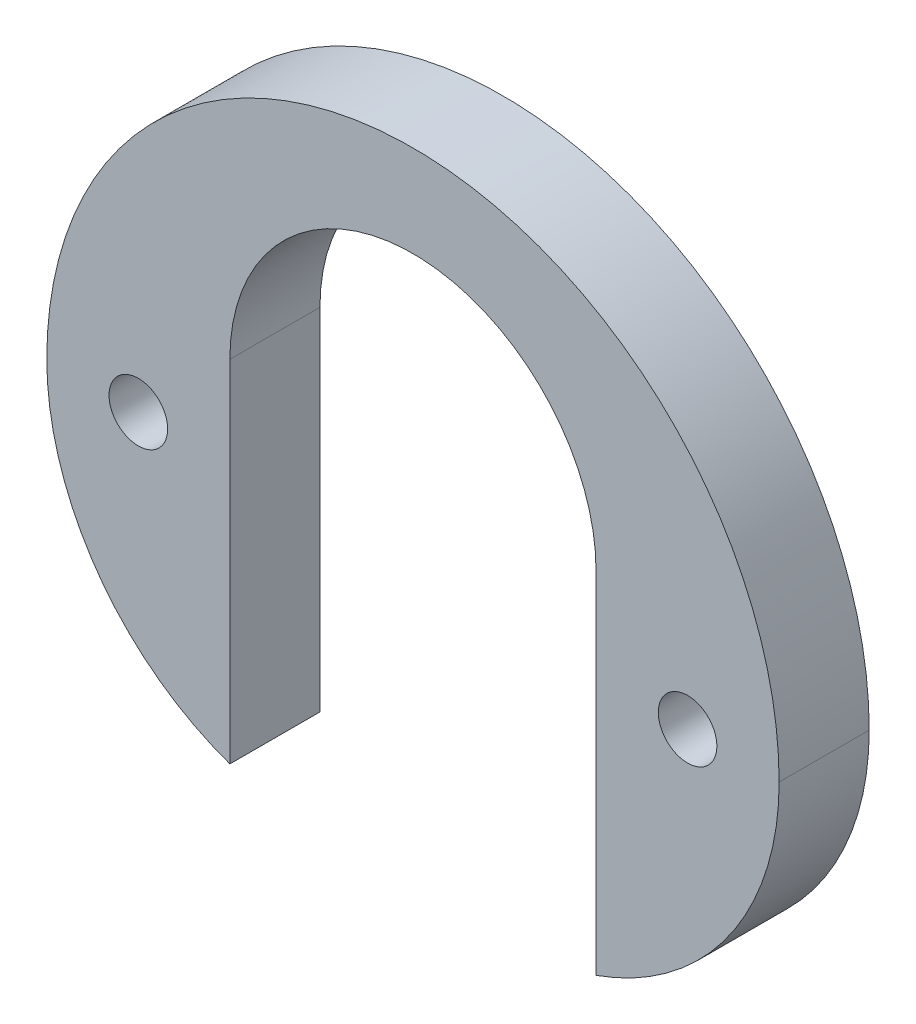
from build123d import *

# Parameters (mm, degrees)
CROQUIS1_R              = 1.016
SALIENTE_EXTRUIR1_DEPTH = 3.1242


with BuildPart() as part:
    # Croquis1 → Saliente-Extruir1 (new body)
    with BuildSketch(Plane.XY):
        with BuildLine():
            Line((-1.7e-08, 9.525), (-3.175, 9.525))
            ThreePointArc((-3.175, 9.525), (-9.910192091, 6.735192091), (-12.7, 0))
            ThreePointArc((-12.7, 0), (-10.952129933, -5.499261314), (-6.35, -8.980256121))
            Line((-6.35, -8.980256121), (-6.35, -3.175))
            Line((-6.35, -3.175), (-6.35, 3.175))
            ThreePointArc((-6.35, 3.175), (-4.490128067, 7.665128054), (-1.7e-08, 9.525))
        make_face()
        with Locations((-9.525, 0)):
            Circle(CROQUIS1_R, mode=Mode.SUBTRACT)
        with BuildLine():
            ThreePointArc((-12.7, 0), (-9.910192091, 6.735192091), (-3.175, 9.525))
            Line((-3.175, 9.525), (-1.7e-08, 9.525))
            Line((-1.7e-08, 9.525), (3.175, 9.525))
            ThreePointArc((3.175, 9.525), (9.910192091, 6.735192091), (12.7, 0))
            ThreePointArc((12.7, 0), (8.980256121, 8.980256121), (0, 12.7))
            ThreePointArc((0, 12.7), (-8.980256121, 8.980256121), (-12.7, 0))
        make_face()
        with BuildLine():
            Line((3.175, 9.525), (-1.7e-08, 9.525))
            ThreePointArc((-1.7e-08, 9.525), (4.490128054, 7.665128067), (6.35, 3.175))
            Line((6.35, 3.175), (6.35, -3.175))
            Line((6.35, -3.175), (6.35, -8.980256121))
            ThreePointArc((6.35, -8.980256121), (10.952129933, -5.499261314), (12.7, 0))
            ThreePointArc((12.7, 0), (9.910192091, 6.735192091), (3.175, 9.525))
        make_face()
        with Locations((9.525, 0)):
            Circle(CROQUIS1_R, mode=Mode.SUBTRACT)
    extrude(amount=SALIENTE_EXTRUIR1_DEPTH)


solid = part.part
